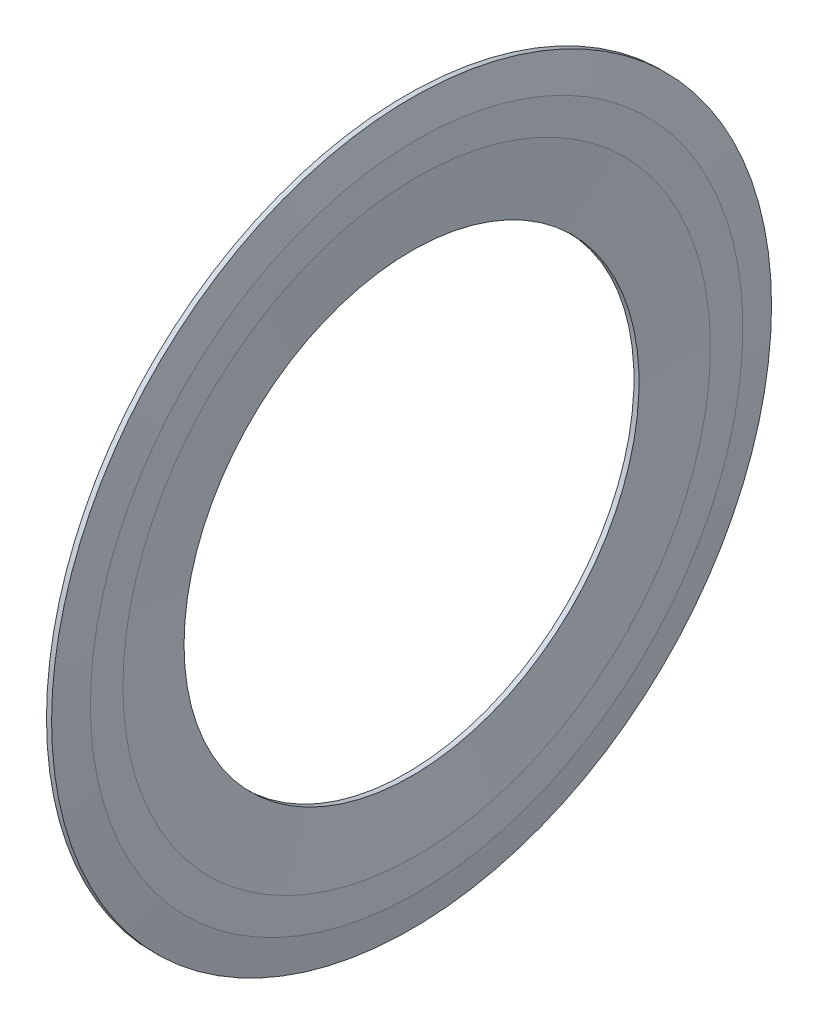
from build123d import *


with BuildPart() as part:
    # Sketch1 → Revolve1 (revolve)
    with BuildSketch(Plane.XY):
        Polygon((0.53, 7.9), (0.707, 7.9), (0.884, 10.2), (0.884, 11.329568043), (0.707, 12.5), (0.53, 12.5), (0.6185, 11.35), (0.53, 10.2), align=None)
    revolve(axis=Axis((0.707, 0, 0), (-1, 0, 0)))


solid = part.part
